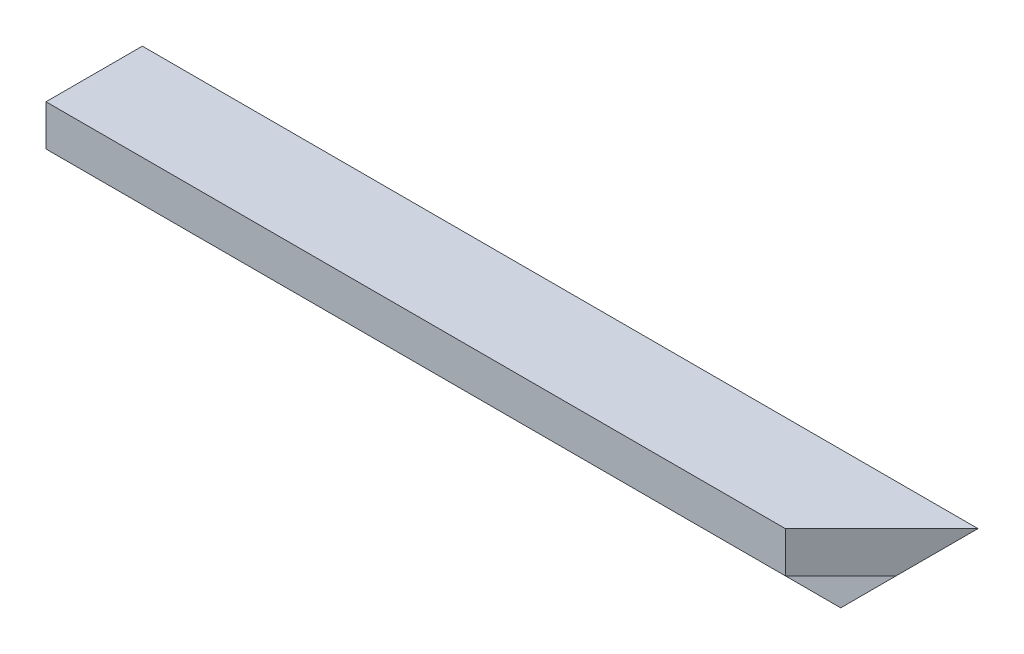
from build123d import *

# Parameters (mm, degrees)
BOSS_EXTRU_1_DEPTH      = 347
ENL_V_MAT_EXTRU_1_DEPTH = 41
ENL_V_MAT_EXTRU_2_DEPTH = 41


with BuildPart() as part:
    # Esquisse1 → Boss.-Extru.1 (new body)
    with BuildSketch(Plane(origin=(0, 0, 0), x_dir=(0, 0, -1), z_dir=(1, 0, 0))):
        Polygon((0, 0), (-40, 0), (-40, -17), (-17, -17), (-17, -40), (0, -40), align=None)
    extrude(amount=-BOSS_EXTRU_1_DEPTH)

    # Esquisse2 → Enlèv. mat.-Extru.1 (cut, through all)
    with BuildSketch(Plane(origin=(0, 0, 0), x_dir=(1, 0, 0), z_dir=(0, 1, 0))):
        Polygon((0, 0), (0, -40), (-40, -40), align=None)
    extrude(amount=-ENL_V_MAT_EXTRU_1_DEPTH, mode=Mode.SUBTRACT)

    # Esquisse3 → Enlèv. mat.-Extru.2 (cut, through all)
    with BuildSketch(Plane(origin=(0, 0, 0), x_dir=(-1, 0, 0), z_dir=(0, 0, -1))):
        Polygon((0, -40), (0, 0), (40, -40), align=None)
    extrude(amount=-ENL_V_MAT_EXTRU_2_DEPTH, mode=Mode.SUBTRACT)


solid = part.part
